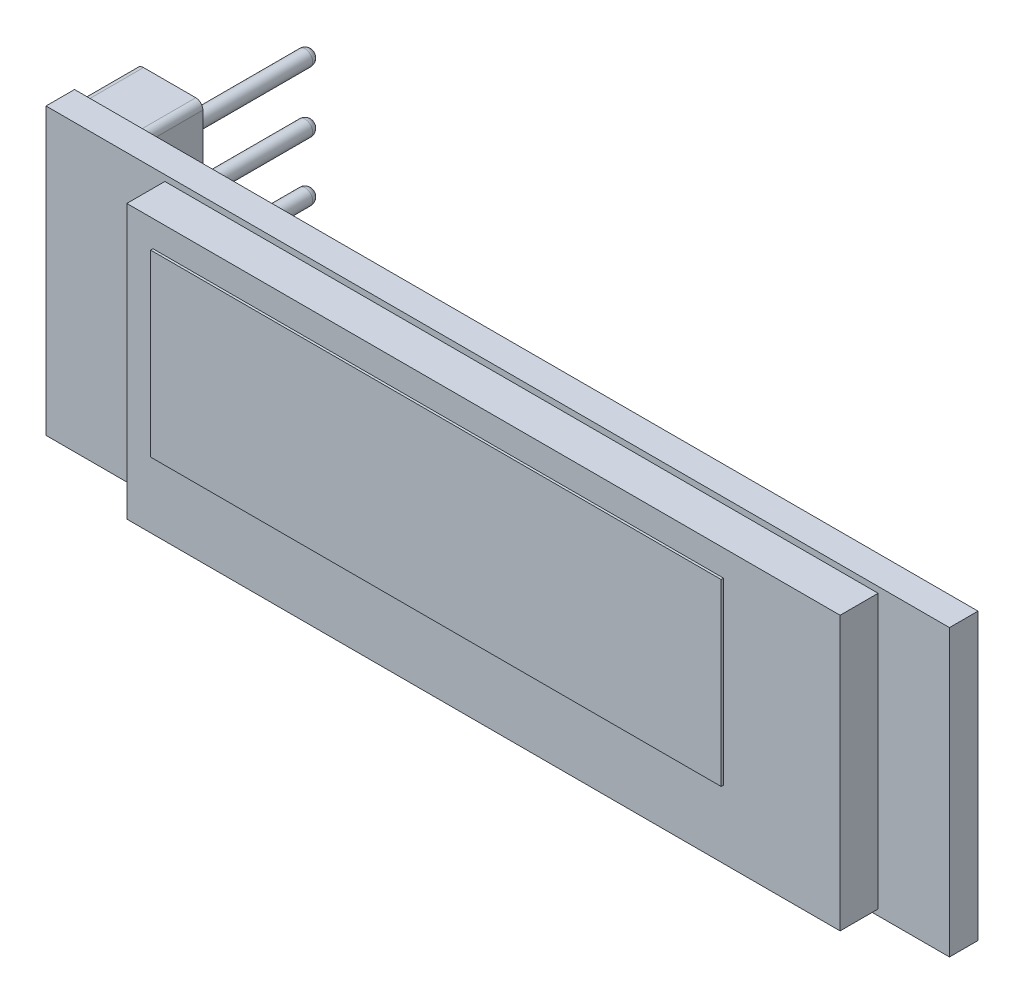
from build123d import *

# Parameters (mm, degrees)
SKETCH1_W           = 38
SKETCH1_H           = 12
BOSS_EXTRUDE1_DEPTH = 1.2
SKETCH2_W           = 30
SKETCH2_H           = 11.5
BOSS_EXTRUDE2_DEPTH = 1.6
SKETCH6_W           = 2.8
SKETCH6_H           = 11.5
BOSS_EXTRUDE4_DEPTH = 2.5
SKETCH5_R           = 0.32
BOSS_EXTRUDE5_DEPTH = 8.5
FILLET1_R           = 0.3
FILLET2_R           = 0.3
SKETCH4_W           = 24
SKETCH4_H           = 7.54
BOSS_EXTRUDE6_DEPTH = 0.1


with BuildPart() as part:
    # Sketch1 → Boss-Extrude1 (new body)
    with BuildSketch(Plane.XY):
        Rectangle(SKETCH1_W, SKETCH1_H)
    extrude(amount=BOSS_EXTRUDE1_DEPTH)

    # Sketch2 → Boss-Extrude2 (add)
    with BuildSketch(Plane.XY.offset(1.2)):
        with Locations((1, 0)):
            Rectangle(SKETCH2_W, SKETCH2_H)
    extrude(amount=BOSS_EXTRUDE2_DEPTH)

    # Sketch6 → Boss-Extrude4 (add)
    with BuildSketch(Plane(origin=(0, 0, 0), x_dir=(-1, 0, 0), z_dir=(0, 0, -1))):
        with Locations((17.5, 0)):
            Rectangle(SKETCH6_W, SKETCH6_H)
    extrude(amount=BOSS_EXTRUDE4_DEPTH)

    # Sketch5 → Boss-Extrude5 (add)
    with BuildSketch(Plane(origin=(0, 0, 0), x_dir=(-1, 0, 0), z_dir=(0, 0, -1))):
        with Locations((17.5, 3.81)):
            Circle(SKETCH5_R)
        with Locations((17.5, 1.25)):
            Circle(SKETCH5_R)
        with Locations((17.5, -1.25)):
            Circle(SKETCH5_R)
        with Locations((17.5, -3.81)):
            Circle(SKETCH5_R)
    extrude(amount=BOSS_EXTRUDE5_DEPTH)

    # Fillet1
    fillet1_edges = [part.edges().sort_by_distance(p)[0] for p in [
        (-17.18, 3.81, -8.5),
        (-17.18, 1.25, -8.5),
        (-17.18, -1.25, -8.5),
        (-17.18, -3.81, -8.5),
    ]]
    fillet(fillet1_edges, radius=FILLET1_R)

    # Fillet2
    fillet2_edges = [part.edges().sort_by_distance(p)[0] for p in [
        (-16.1, 5.75, -1.25),
        (-16.1, -5.75, -1.25),
        (-18.9, -5.75, -1.25),
        (-18.9, 5.75, -1.25),
    ]]
    fillet(fillet2_edges, radius=FILLET2_R)

    # Sketch4 → Boss-Extrude6 (add)
    with BuildSketch(Plane.XY.offset(2.8)):
        with Locations((-0.9, 0.88)):
            Rectangle(SKETCH4_W, SKETCH4_H)
    extrude(amount=BOSS_EXTRUDE6_DEPTH)


solid = part.part
